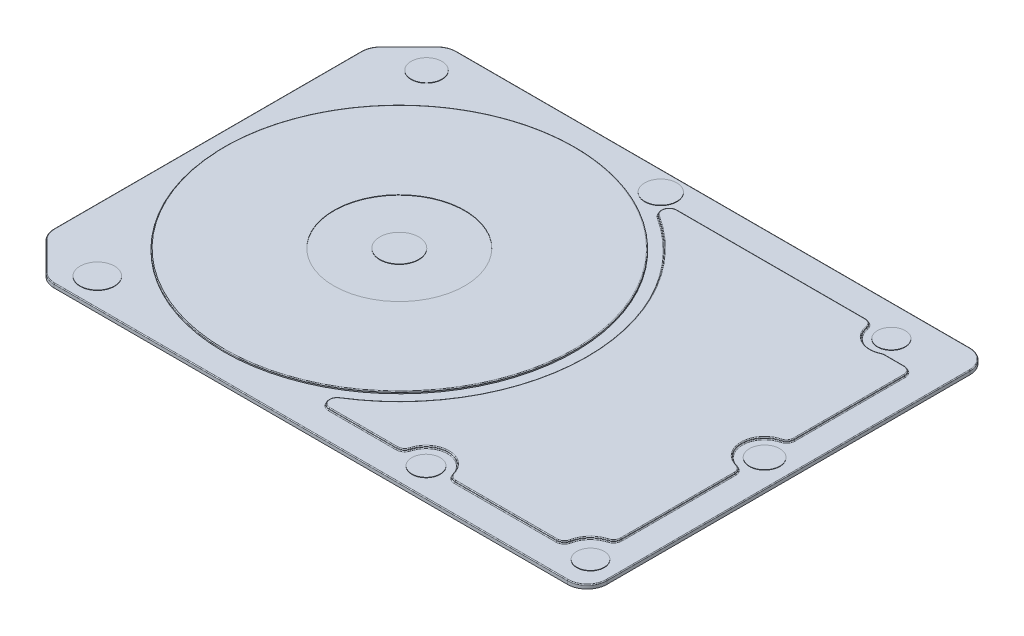
from build123d import *

# Parameters (mm, degrees)
COVER_BASE_DEPTH       = 1
FILLET1_R              = 0.2
SKETCH2_R              = 44.45
DISK_BULB_DEPTH        = 0.5
FILLET2_R              = 0.2
HARDWARE_BULGING_DEPTH = 0.5
FILLET3_R              = 0.2
FILLET4_R              = 0.2
SKETCH4_R              = 3.511132636
SKETCH4_R_2            = 3.834161636
SKETCH4_R_3            = 3.471926453
SKETCH4_R_4            = 3.585320712
SKETCH4_R_5            = 4.353085211
SKETCH4_R_6            = 3.89531807
SKETCH4_R_7            = 4.066876422
SCREW_CAPS_DEPTH       = 0.1
SKETCH5_R              = 16.567036965
SKETCH5_R_2            = 4.925147254
CUT_EXTRUDE1_DEPTH     = 0.1


with BuildPart() as part:
    # Sketch1 → cover base (new body)
    with BuildSketch(Plane(origin=(0, 0, 0), x_dir=(1, 0, 0), z_dir=(0, 1, 0))):
        with BuildLine():
            Line((-72.030533906, 42.389466094), (-64.959466094, 49.460533906))
            ThreePointArc((-64.959466094, 49.460533906), (-63.33734935, 50.544397663), (-61.423932188, 50.925))
            Line((-61.423932188, 50.925), (68.495, 50.925))
            ThreePointArc((68.495, 50.925), (72.030533906, 49.460533906), (73.495, 45.925))
            Line((73.495, 45.925), (73.495, -45.925))
            ThreePointArc((73.495, -45.925), (72.030533906, -49.460533906), (68.495, -50.925))
            Line((68.495, -50.925), (-61.423932188, -50.925))
            ThreePointArc((-61.423932188, -50.925), (-63.33734935, -50.544397663), (-64.959466094, -49.460533906))
            Line((-64.959466094, -49.460533906), (-72.030533906, -42.389466094))
            ThreePointArc((-72.030533906, -42.389466094), (-73.114397663, -40.76734935), (-73.495, -38.853932188))
            Line((-73.495, -38.853932188), (-73.495, 38.853932188))
            ThreePointArc((-73.495, 38.853932188), (-73.114397663, 40.76734935), (-72.030533906, 42.389466094))
        make_face()
    extrude(amount=COVER_BASE_DEPTH)

    # Fillet1
    fillet1_edges = [part.edges().sort_by_distance(p)[0] for p in [
        (72.030533906, 1, 49.460533906),
        (73.495, 1, 0),
        (72.030533906, 1, -49.460533906),
        (3.535533906, 1, -50.925),
        (-63.33734935, 1, -50.544397663),
        (-68.495, 1, -45.925),
        (-73.114397663, 1, -40.76734935),
        (-73.495, 1, 0),
        (-73.114397663, 1, 40.76734935),
        (-68.495, 1, 45.925),
        (-63.33734935, 1, 50.544397663),
        (3.535533906, 1, 50.925),
    ]]
    fillet(fillet1_edges, radius=FILLET1_R)

    # Sketch2 → disk bulb (add)
    with BuildSketch(Plane(origin=(0, 1, 0), x_dir=(1, 0, 0), z_dir=(0, 1, 0))):
        with Locations((-25, 0)):
            Circle(SKETCH2_R)
    extrude(amount=DISK_BULB_DEPTH)

    # Fillet2
    fillet2_edges = [part.edges().sort_by_distance(p)[0] for p in [
        (-69.45, 1.5, 0),
    ]]
    fillet(fillet2_edges, radius=FILLET2_R)

    # Sketch3 → hardware bulging (add)
    with BuildSketch(Plane(origin=(0, 1, 0), x_dir=(1, 0, 0), z_dir=(0, 1, 0))):
        with BuildLine():
            Line((1.2049115, -43.92168913), (18.31702258, -43.92168913))
            ThreePointArc((18.31702258, -43.92168913), (19.532089041, -43.510277653), (20.247263214, -42.445302625))
            ThreePointArc((20.247263214, -42.445302625), (25.689791432, -38.28246662), (31.13231965, -42.445302625))
            ThreePointArc((31.13231965, -42.445302625), (31.847493823, -43.510277653), (33.062560284, -43.92168913))
            Line((33.062560284, -43.92168913), (58.733082901, -43.92168913))
            ThreePointArc((58.733082901, -43.92168913), (59.997770473, -43.471064922), (60.69255921, -42.322254476))
            ThreePointArc((60.69255921, -42.322254476), (62.280717073, -39.231663214), (65.242955695, -37.415309146))
            ThreePointArc((65.242955695, -37.415309146), (66.291911362, -36.69697407), (66.69598968, -35.491555477))
            Line((66.69598968, -35.491555477), (66.69598968, -6.751125846))
            ThreePointArc((66.69598968, -6.751125846), (66.281625338, -5.532208473), (65.210230118, -4.818366996))
            ThreePointArc((65.210230118, -4.818366996), (60.917527109, 0.765820341), (65.210230118, 6.350007678))
            ThreePointArc((65.210230118, 6.350007678), (66.281625338, 7.063849155), (66.69598968, 8.282766528))
            Line((66.69598968, 8.282766528), (66.69598968, 36.151776978))
            ThreePointArc((66.69598968, 36.151776978), (66.110203243, 37.56599054), (64.69598968, 38.151776978))
            Line((64.69598968, 38.151776978), (59.792786532, 38.151776978))
            ThreePointArc((59.792786532, 38.151776978), (59.36324209, 38.10510531), (58.953745204, 37.967268551))
            ThreePointArc((58.953745204, 37.967268551), (54.205548794, 38.086123373), (51.407747033, 41.924326198))
            ThreePointArc((51.407747033, 41.924326198), (50.724798354, 43.112559861), (49.437237405, 43.582139394))
            Line((49.437237405, 43.582139394), (1.740439218, 43.582139394))
            ThreePointArc((1.740439218, 43.582139394), (-0.178464151, 42.145885668), (0.658664595, 39.899949255))
            ThreePointArc((0.658664595, 39.899949255), (22.437121192, -0.304224294), (0.144801453, -40.225762631))
            ThreePointArc((0.144801453, -40.225762631), (-0.717567759, -42.47311773), (1.2049115, -43.92168913))
        make_face()
    extrude(amount=HARDWARE_BULGING_DEPTH)

    # Fillet3
    fillet3_edges = [part.edges().sort_by_distance(p)[0] for p in [
        (66.291911362, 1.5, 36.69697407),
        (66.69598968, 1.5, 21.121340662),
        (66.281625338, 1.5, 5.532208473),
        (60.917527109, 1.5, -0.765820341),
        (66.281625338, 1.5, -7.063849155),
        (66.69598968, 1.5, -22.217271753),
        (66.110203243, 1.5, -37.56599054),
        (62.244388106, 1.5, -38.151776978),
        (59.36324209, 1.5, -38.10510531),
        (54.205548794, 1.5, -38.086123373),
        (50.724798354, 1.5, -43.112559861),
        (25.588838312, 1.5, -43.582139394),
        (-0.178464151, 1.5, -42.145885668),
        (22.437121192, 1.5, 0.304224294),
        (-0.717567759, 1.5, 42.47311773),
        (9.76096704, 1.5, 43.92168913),
        (19.532089041, 1.5, 43.510277653),
        (25.689791432, 1.5, 38.28246662),
        (31.847493823, 1.5, 43.510277653),
        (45.897821593, 1.5, 43.92168913),
        (59.997770473, 1.5, 43.471064922),
        (62.280717073, 1.5, 39.231663214),
    ]]
    fillet(fillet3_edges, radius=FILLET3_R)

    # Fillet4
    fillet4_edges = [part.edges().sort_by_distance(p)[0] for p in [
        (50.724798354, 1, -43.112559861),
        (25.588838312, 1, -43.582139394),
        (-0.178464151, 1, -42.145885668),
        (22.437121192, 1, 0.304224294),
        (-0.717567759, 1, 42.47311773),
        (9.76096704, 1, 43.92168913),
        (19.532089041, 1, 43.510277653),
        (25.689791432, 1, 38.28246662),
        (31.847493823, 1, 43.510277653),
        (45.897821593, 1, 43.92168913),
        (59.997770473, 1, 43.471064922),
        (62.280717073, 1, 39.231663214),
        (66.291911362, 1, 36.69697407),
        (66.69598968, 1, 21.121340662),
        (66.281625338, 1, 5.532208473),
        (60.917527109, 1, -0.765820341),
        (66.281625338, 1, -7.063849155),
        (66.69598968, 1, -22.217271753),
        (66.110203243, 1, -37.56599054),
        (62.244388106, 1, -38.151776978),
        (59.36324209, 1, -38.10510531),
        (54.205548794, 1, -38.086123373),
    ]]
    fillet(fillet4_edges, radius=FILLET4_R)

    # Sketch4 → screw caps (add)
    with BuildSketch(Plane(origin=(0, 1, 0), x_dir=(1, 0, 0), z_dir=(0, 1, 0))):
        with Locations((56.700216286, 42.843384452)):
            Circle(SKETCH4_R)
        with Locations((66.69598968, 0.765820341)):
            Circle(SKETCH4_R_2)
        with Locations((67.00500461, -43.6126742)):
            Circle(SKETCH4_R_3)
        with Locations((25.689791432, -43.92168913)):
            Circle(SKETCH4_R_4)
        with Locations((-57.506145591, -43.92168913)):
            Circle(SKETCH4_R_5)
        with Locations((-60.95659819, 42.843384452)):
            Circle(SKETCH4_R_6)
        with Locations((-4.585055317, 45.771090055)):
            Circle(SKETCH4_R_7)
    extrude(amount=SCREW_CAPS_DEPTH)

    # Sketch5 → Cut-Extrude1 (cut)
    with BuildSketch(Plane(origin=(0, 1.5, 0), x_dir=(1, 0, 0), z_dir=(0, 1, 0))):
        with Locations((-25, 0)):
            Circle(SKETCH5_R)
        with Locations((-25, 0)):
            Circle(SKETCH5_R_2, mode=Mode.SUBTRACT)
    extrude(amount=-CUT_EXTRUDE1_DEPTH, mode=Mode.SUBTRACT)


solid = part.part
